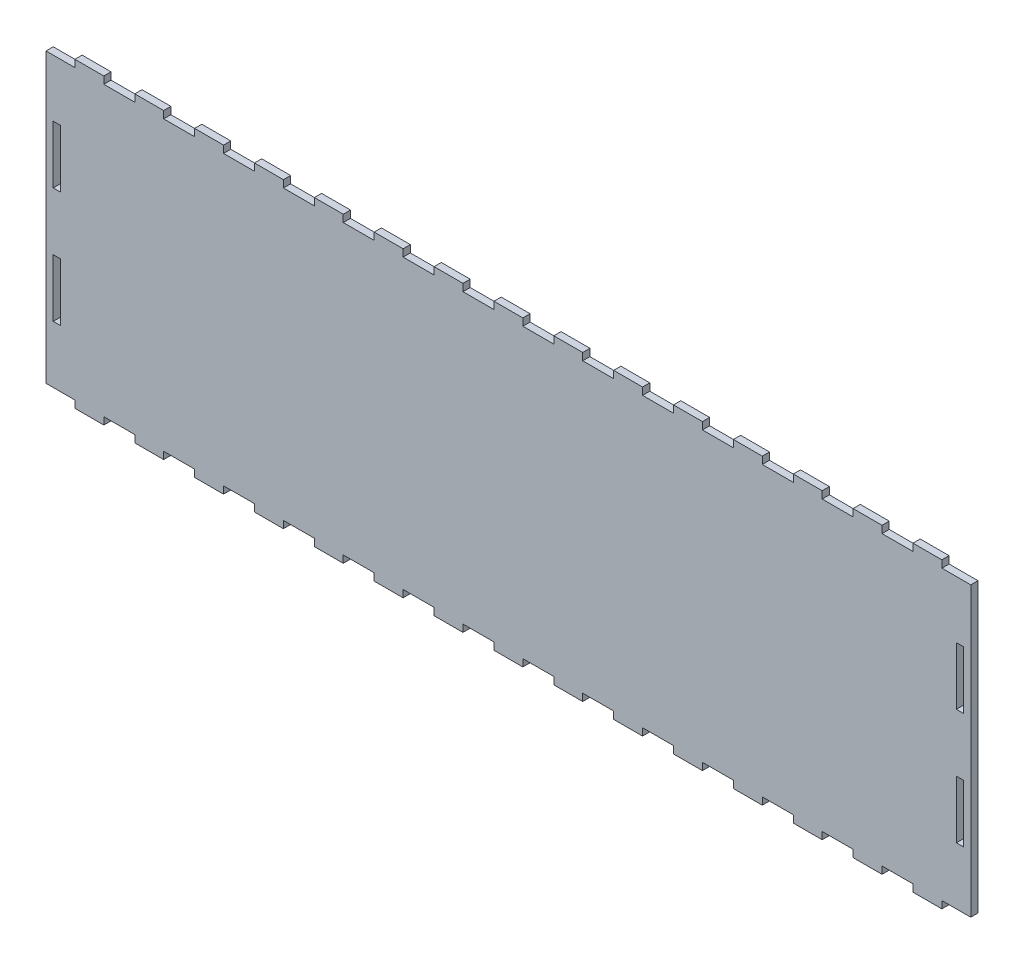
from build123d import *

# Parameters (mm, degrees)
SKETCH1_W           = 3.175
SKETCH1_H           = 25.4
BOSS_EXTRUDE1_DEPTH = 3.175


with BuildPart() as part:
    # Sketch1 → Boss-Extrude1 (new body)
    with BuildSketch(Plane.XY):
        Polygon((65.314285714, 126.5047), (65.214285714, 126.5047), (51.807142857, 126.5047), (51.707142857, 126.5047), (51.707142857, 129.6797), (39.007142857, 129.6797), (39.007142857, 126.5047), (38.907142857, 126.5047), (25.5, 126.5047), (25.4, 126.5047), (25.4, 129.6797), (12.7, 129.6797), (12.7, 126.5047), (12.6, 126.5047), (0, 126.5047), (0, 0), (12.6, 0), (12.7, 0), (12.7, -3.175), (25.4, -3.175), (25.4, 0), (25.5, 0), (38.907142857, 0), (39.007142857, 0), (39.007142857, -3.175), (51.707142857, -3.175), (51.707142857, 0), (51.807142857, 0), (65.214285714, 0), (65.314285714, 0), (65.314285714, -3.175), (78.014285714, -3.175), (78.014285714, 0), (78.114285714, 0), (91.521428571, 0), (91.621428571, 0), (91.621428571, -3.175), (104.321428571, -3.175), (104.321428571, 0), (104.421428571, 0), (117.828571429, 0), (117.928571429, 0), (117.928571429, -3.175), (130.628571429, -3.175), (130.628571429, 0), (130.728571429, 0), (144.135714286, 0), (144.235714286, 0), (144.235714286, -3.175), (156.935714286, -3.175), (156.935714286, 0), (157.035714286, 0), (170.442857143, 0), (170.542857143, 0), (170.542857143, -3.175), (183.242857143, -3.175), (183.242857143, 0), (183.342857143, 0), (196.75, 0), (196.85, 0), (196.85, -3.175), (209.55, -3.175), (209.55, 0), (209.65, 0), (223.057142857, 0), (223.157142857, 0), (223.157142857, -3.175), (235.857142857, -3.175), (235.857142857, 0), (235.957142857, 0), (249.364285714, 0), (249.464285714, 0), (249.464285714, -3.175), (262.164285714, -3.175), (262.164285714, 0), (262.264285714, 0), (275.671428571, 0), (275.771428571, 0), (275.771428571, -3.175), (288.471428571, -3.175), (288.471428571, 0), (288.571428571, 0), (301.978571429, 0), (302.078571429, 0), (302.078571429, -3.175), (314.778571429, -3.175), (314.778571429, 0), (314.878571429, 0), (328.285714286, 0), (328.385714286, 0), (328.385714286, -3.175), (341.085714286, -3.175), (341.085714286, 0), (341.185714286, 0), (354.592857143, 0), (354.692857143, 0), (354.692857143, -3.175), (367.392857143, -3.175), (367.392857143, 0), (367.492857143, 0), (380.9, 0), (381, 0), (381, -3.175), (393.7, -3.175), (393.7, 0), (393.8, 0), (406.4, 0), (406.4, 126.5047), (393.8, 126.5047), (393.7, 126.5047), (393.7, 129.6797), (381, 129.6797), (381, 126.5047), (380.9, 126.5047), (367.492857143, 126.5047), (367.392857143, 126.5047), (367.392857143, 129.6797), (354.692857143, 129.6797), (354.692857143, 126.5047), (354.592857143, 126.5047), (341.185714286, 126.5047), (341.085714286, 126.5047), (341.085714286, 129.6797), (328.385714286, 129.6797), (328.385714286, 126.5047), (328.285714286, 126.5047), (314.878571429, 126.5047), (314.778571429, 126.5047), (314.778571429, 129.6797), (302.078571429, 129.6797), (302.078571429, 126.5047), (301.978571429, 126.5047), (288.571428571, 126.5047), (288.471428571, 126.5047), (288.471428571, 129.6797), (275.771428571, 129.6797), (275.771428571, 126.5047), (275.671428571, 126.5047), (262.264285714, 126.5047), (262.164285714, 126.5047), (262.164285714, 129.6797), (249.464285714, 129.6797), (249.464285714, 126.5047), (249.364285714, 126.5047), (235.957142857, 126.5047), (235.857142857, 126.5047), (235.857142857, 129.6797), (223.157142857, 129.6797), (223.157142857, 126.5047), (223.057142857, 126.5047), (209.65, 126.5047), (209.55, 126.5047), (209.55, 129.6797), (196.85, 129.6797), (196.85, 126.5047), (196.75, 126.5047), (183.342857143, 126.5047), (183.242857143, 126.5047), (183.242857143, 129.6797), (170.542857143, 129.6797), (170.542857143, 126.5047), (170.442857143, 126.5047), (157.035714286, 126.5047), (156.935714286, 126.5047), (156.935714286, 129.6797), (144.235714286, 129.6797), (144.235714286, 126.5047), (144.135714286, 126.5047), (130.728571429, 126.5047), (130.628571429, 126.5047), (130.628571429, 129.6797), (117.928571429, 129.6797), (117.928571429, 126.5047), (117.828571429, 126.5047), (104.421428571, 126.5047), (104.321428571, 126.5047), (104.321428571, 129.6797), (91.621428571, 129.6797), (91.621428571, 126.5047), (91.521428571, 126.5047), (78.114285714, 126.5047), (78.014285714, 126.5047), (78.014285714, 129.6797), (65.314285714, 129.6797), align=None)
        with Locations((401.6375, 88.65235)):
            Rectangle(SKETCH1_W, SKETCH1_H, mode=Mode.SUBTRACT)
        with Locations((401.6375, 37.85235)):
            Rectangle(SKETCH1_W, SKETCH1_H, mode=Mode.SUBTRACT)
        with Locations((4.7625, 88.65235)):
            Rectangle(SKETCH1_W, SKETCH1_H, mode=Mode.SUBTRACT)
        with Locations((4.7625, 37.85235)):
            Rectangle(SKETCH1_W, SKETCH1_H, mode=Mode.SUBTRACT)
    extrude(amount=BOSS_EXTRUDE1_DEPTH)


solid = part.part
